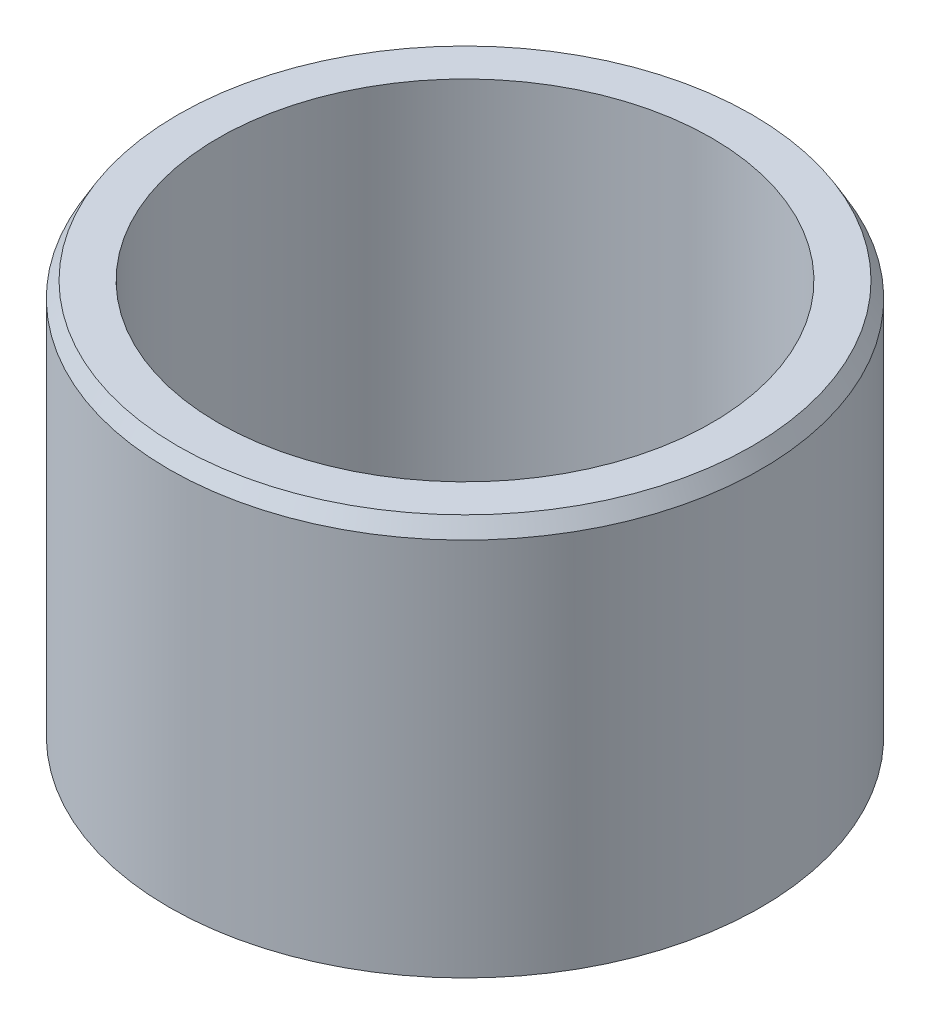
from build123d import *

# Parameters (mm, degrees)
SKETCH1_W      = 1.5875
SKETCH1_H      = 12.7
CHAMFER1_SIZE  = 0.50038
CHAMFER1_SIZE2 = 0.288894528


with BuildPart() as part:
    # Sketch1 → Revolve1 (revolve)
    with BuildSketch(Plane.XY):
        with Locations((8.73125, 6.35)):
            Rectangle(SKETCH1_W, SKETCH1_H)
    revolve(axis=Axis((0, 21.439877717, 0), (0, -1, 0)))

    # Chamfer1
    chamfer1_edges = [part.edges().sort_by_distance(p)[0] for p in [
        (-9.525, 12.7, 0),
    ]]
    chamfer1_side = [part.faces().sort_by_distance(p)[0] for p in [
        (-9.525, 6.35, 0),
    ]]
    chamfer(chamfer1_edges, length=CHAMFER1_SIZE, length2=CHAMFER1_SIZE2, reference=chamfer1_side[0])


solid = part.part
